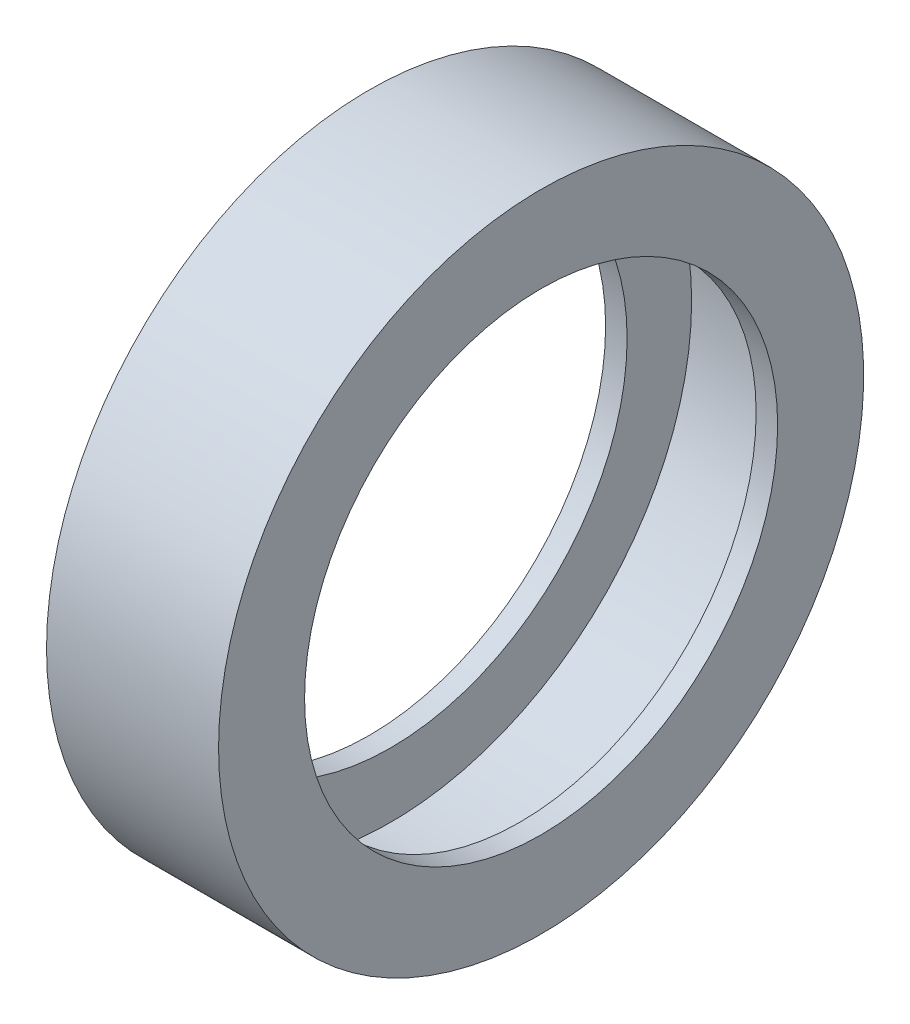
from build123d import *


with BuildPart() as part:
    # 草圖1 → 旋轉1 (revolve)
    with BuildSketch(Plane.XY):
        Polygon((20, 75), (-20, 75), (-20, 55), (-15, 55), (-15, 70), (15, 70), (15, 55), (20, 55), align=None)
    revolve(axis=Axis((-91.970106672, 0, 0), (1, 0, 0)))


solid = part.part
